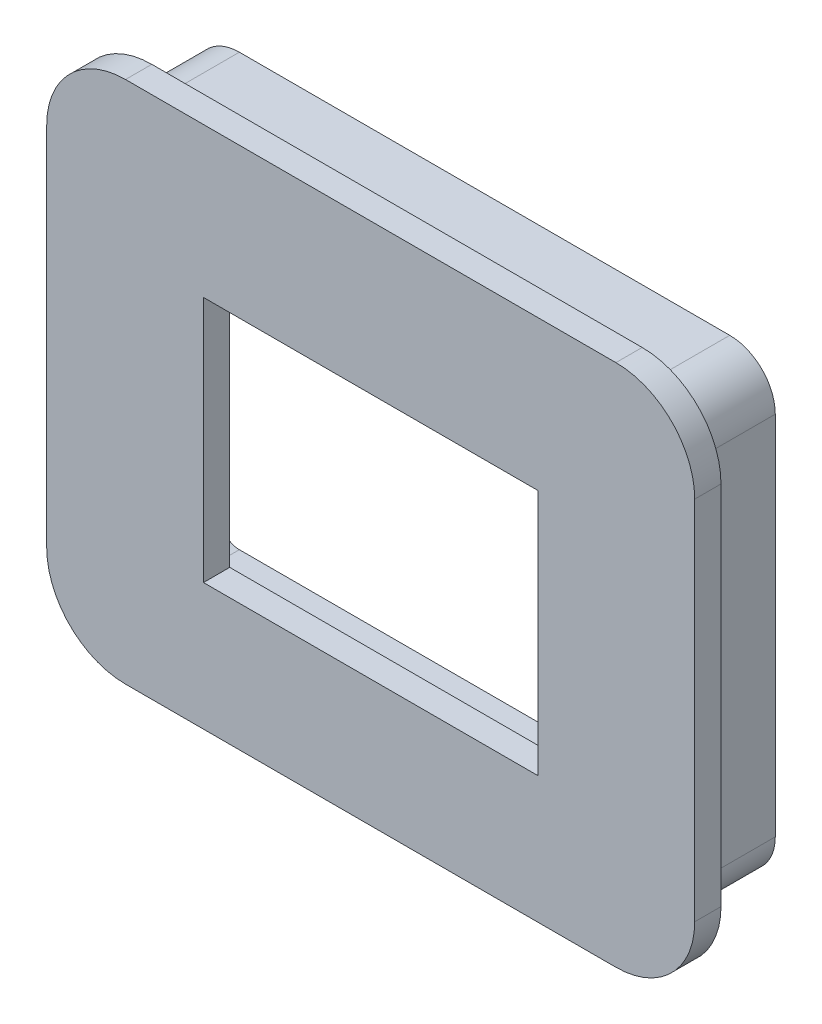
from build123d import *

# Parameters (mm, degrees)
EXTRUDE_1_DEPTH     = 1.5
EXTRUDE_2_DEPTH     = 5
SKETCH_4_W          = 19.1
SKETCH_4_H          = 14.1
CUT_EXTRUDE_1_DEPTH = 1.5


with BuildPart() as part:
    # 草图1 → 凸台-拉伸1 (new body)
    with BuildSketch(Plane.XY):
        with BuildLine():
            Line((0, 22.9), (-28, 22.9))
            ThreePointArc((-28, 22.9), (-31.181980515, 21.581980515), (-32.5, 18.4))
            Line((-32.5, 18.4), (-32.5, -2.5))
            ThreePointArc((-32.5, -2.5), (-31.181980515, -5.681980515), (-28, -7))
            Line((-28, -7), (0, -7))
            ThreePointArc((0, -7), (3.181980515, -5.681980515), (4.5, -2.5))
            Line((4.5, -2.5), (4.5, 18.4))
            ThreePointArc((4.5, 18.4), (3.181980515, 21.581980515), (0, 22.9))
        make_face()
    extrude(amount=EXTRUDE_1_DEPTH)

    # 草图4 → 切除-拉伸1 (cut)
    with BuildSketch(Plane.XY.offset(1.5)):
        with Locations((-14, 7.3)):
            Rectangle(SKETCH_4_W, SKETCH_4_H)
    extrude(amount=-CUT_EXTRUDE_1_DEPTH, mode=Mode.SUBTRACT)


with BuildPart() as body_2:
    # 草图3 → 凸台-拉伸2 (new body)
    with BuildSketch(Plane.XY):
        with BuildLine():
            Line((-25.232655095, 21), (-3.217775858, 21))
            Line((-3.217775858, 21), (0, 21))
            ThreePointArc((0, 21), (1.838477631, 20.238477631), (2.6, 18.4))
            Line((2.6, 18.4), (2.6, -2.5))
            ThreePointArc((2.6, -2.5), (1.838477631, -4.338477631), (0, -5.1))
            Line((0, -5.1), (-28, -5.1))
            ThreePointArc((-28, -5.1), (-29.838477631, -4.338477631), (-30.6, -2.5))
            Line((-30.6, -2.5), (-30.6, 18.4))
            ThreePointArc((-30.6, 18.4), (-29.838477631, 20.238477631), (-28, 21))
            Line((-28, 21), (-25.232655095, 21))
        make_face()
        with BuildLine():
            Line((-25.232655095, 19.5), (-3.217775858, 19.5))
            Line((-3.217775858, 19.5), (0, 19.5))
            ThreePointArc((0, 19.5), (0.777817459, 19.177817459), (1.1, 18.4))
            Line((1.1, 18.4), (1.1, -2.5))
            ThreePointArc((1.1, -2.5), (0.777817459, -3.277817459), (0, -3.6))
            Line((0, -3.6), (-28, -3.6))
            ThreePointArc((-28, -3.6), (-28.777817459, -3.277817459), (-29.1, -2.5))
            Line((-29.1, -2.5), (-29.1, 18.4))
            ThreePointArc((-29.1, 18.4), (-28.777817459, 19.177817459), (-28, 19.5))
            Line((-28, 19.5), (-25.232655095, 19.5))
        make_face(mode=Mode.SUBTRACT)
    extrude(amount=-EXTRUDE_2_DEPTH)


solid = Compound([part.part, body_2.part])
